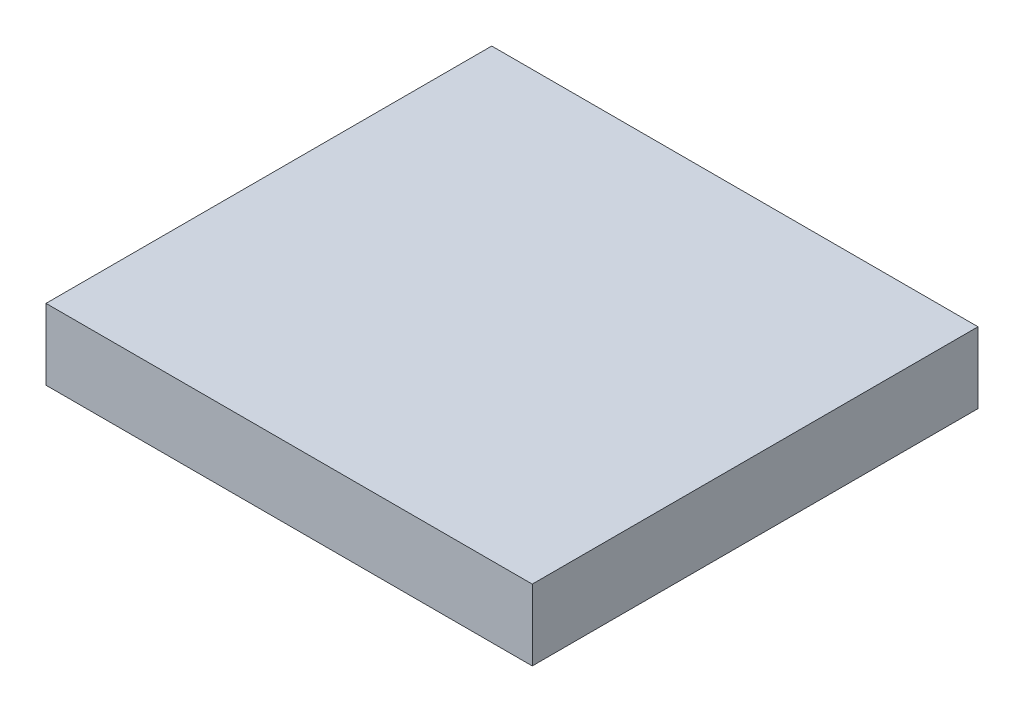
from build123d import *

# Parameters (mm, degrees)
SKETCH1_W           = 304.8
SKETCH1_H           = 279.4
BOSS_EXTRUDE1_DEPTH = 44.45


with BuildPart() as part:
    # Sketch1 → Boss-Extrude1 (new body)
    with BuildSketch(Plane(origin=(0, 0, 0), x_dir=(1, 0, 0), z_dir=(0, 1, 0))):
        with Locations((152.4, 139.7)):
            Rectangle(SKETCH1_W, SKETCH1_H)
    extrude(amount=BOSS_EXTRUDE1_DEPTH)


solid = part.part
